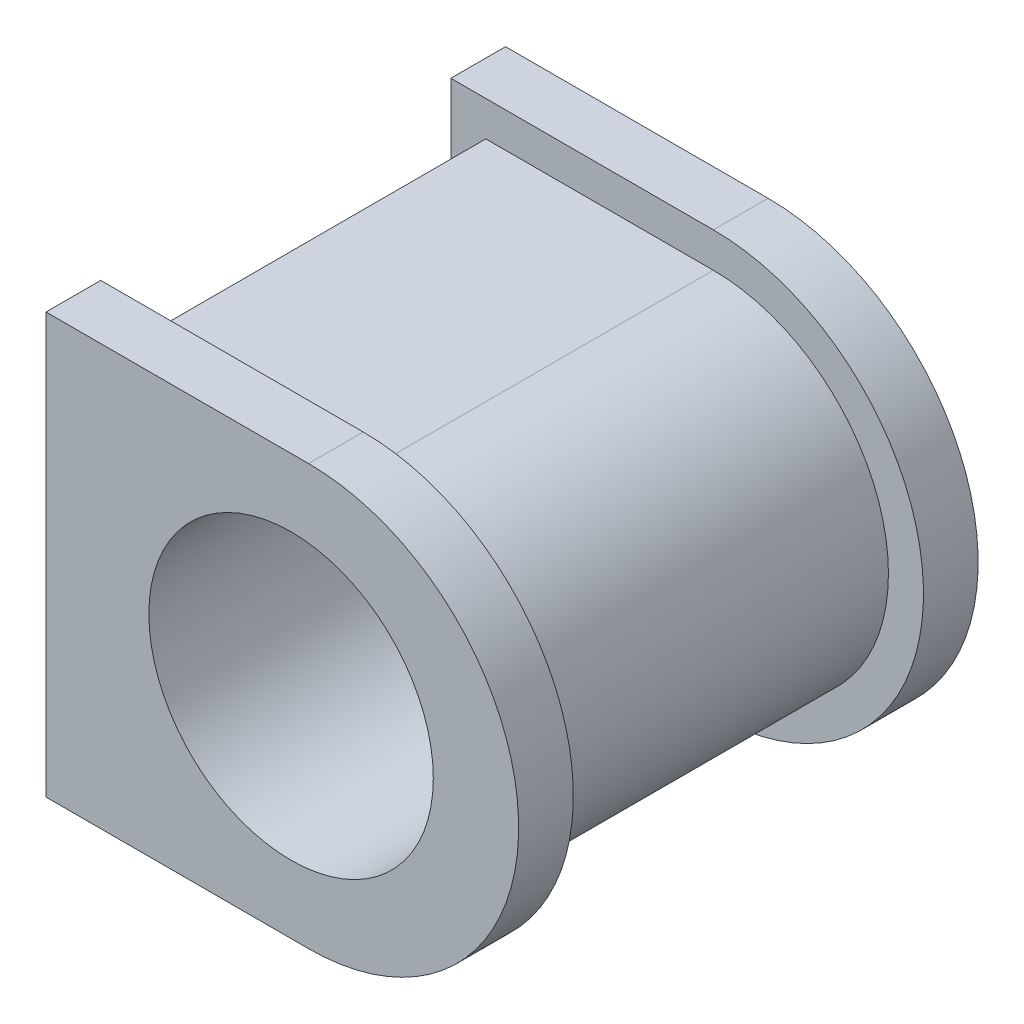
from build123d import *

# Parameters (mm, degrees)
SKETCH1_R           = 32.5
BOSS_EXTRUDE1_DEPTH = 80
SKETCH2_R           = 32.5
BOSS_EXTRUDE2_DEPTH = 12.5
SKETCH6_R           = 32.5
BOSS_EXTRUDE4_DEPTH = 12.5


with BuildPart() as part:
    # Sketch1 → Boss-Extrude1 (new body)
    with BuildSketch(Plane.XY):
        with BuildLine():
            Line((-225.792643224, 137.875019839), (-173.792643224, 137.875019839))
            ThreePointArc((-173.792643224, 137.875019839), (-133.792643224, 97.875019839), (-173.792643224, 57.875019839))
            Line((-173.792643224, 57.875019839), (-225.792643224, 57.875019839))
            Line((-225.792643224, 57.875019839), (-225.792643224, 137.875019839))
        make_face()
        with Locations((-177.792643224, 97.875019839)):
            Circle(SKETCH1_R, mode=Mode.SUBTRACT)
    extrude(amount=BOSS_EXTRUDE1_DEPTH)

    # Sketch2 → Boss-Extrude2 (add)
    with BuildSketch(Plane.XY.offset(80)):
        with BuildLine():
            Line((-173.792643224, 49.875019839), (-233.792643224, 49.875019839))
            Line((-233.792643224, 49.875019839), (-233.792643224, 145.875019839))
            Line((-233.792643224, 145.875019839), (-173.792643224, 145.875019839))
            ThreePointArc((-173.792643224, 145.875019839), (-125.792643224, 97.875019839), (-173.792643224, 49.875019839))
        make_face()
        with BuildLine():
            Line((-225.792643224, 137.875019839), (-225.792643224, 57.875019839))
            Line((-225.792643224, 57.875019839), (-173.792643224, 57.875019839))
            ThreePointArc((-173.792643224, 57.875019839), (-133.792643224, 97.875019839), (-173.792643224, 137.875019839))
            Line((-173.792643224, 137.875019839), (-225.792643224, 137.875019839))
        make_face(mode=Mode.SUBTRACT)
        with BuildLine():
            Line((-173.792643224, 137.875019839), (-225.792643224, 137.875019839))
            Line((-225.792643224, 137.875019839), (-225.792643224, 57.875019839))
            Line((-225.792643224, 57.875019839), (-173.792643224, 57.875019839))
            ThreePointArc((-173.792643224, 57.875019839), (-133.792643224, 97.875019839), (-173.792643224, 137.875019839))
        make_face()
        with Locations((-177.792643224, 97.875019839)):
            Circle(SKETCH2_R, mode=Mode.SUBTRACT)
    extrude(amount=BOSS_EXTRUDE2_DEPTH)

    # Sketch6 → Boss-Extrude4 (add)
    with BuildSketch(Plane(origin=(0, 0, 0), x_dir=(-1, 0, 0), z_dir=(0, 0, -1))):
        with BuildLine():
            Line((233.792643224, 145.875019839), (173.792643224, 145.875019839))
            ThreePointArc((173.792643224, 145.875019839), (125.792643224, 97.875019839), (173.792643224, 49.875019839))
            Line((173.792643224, 49.875019839), (233.792643224, 49.875019839))
            Line((233.792643224, 49.875019839), (233.792643224, 145.875019839))
        make_face()
        with Locations((177.792643224, 97.875019839)):
            Circle(SKETCH6_R, mode=Mode.SUBTRACT)
    extrude(amount=BOSS_EXTRUDE4_DEPTH)


solid = part.part
